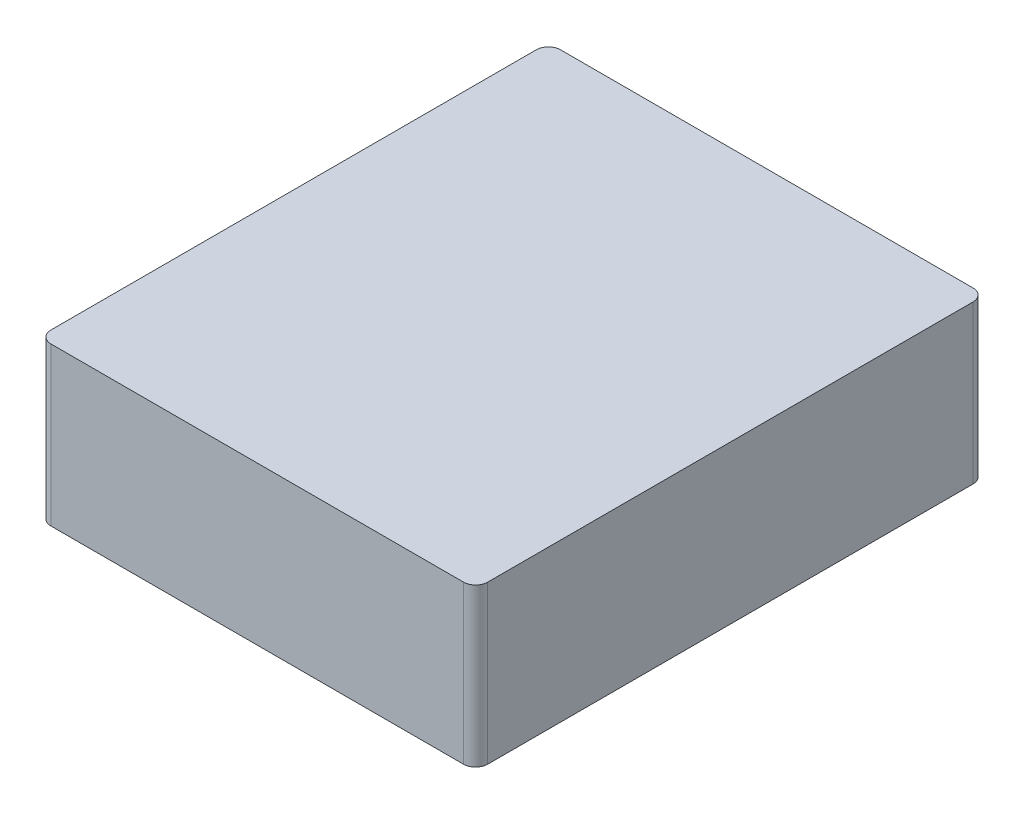
from build123d import *

# Parameters (mm, degrees)
CROQUIS1_W              = 36
CROQUIS1_H              = 42
SALIENTE_EXTRUIR1_DEPTH = 13
REDONDEO1_R             = 1


with BuildPart() as part:
    # Croquis1 → Saliente-Extruir1 (new body)
    with BuildSketch(Plane(origin=(0, 0, 0), x_dir=(1, 0, 0), z_dir=(0, 1, 0))):
        Rectangle(CROQUIS1_W, CROQUIS1_H)
    extrude(amount=SALIENTE_EXTRUIR1_DEPTH)

    # Redondeo1
    redondeo1_edges = [part.edges().sort_by_distance(p)[0] for p in [
        (18, 6.5, 21),
        (-18, 6.5, 21),
        (-18, 6.5, -21),
        (18, 6.5, -21),
    ]]
    fillet(redondeo1_edges, radius=REDONDEO1_R)


solid = part.part
